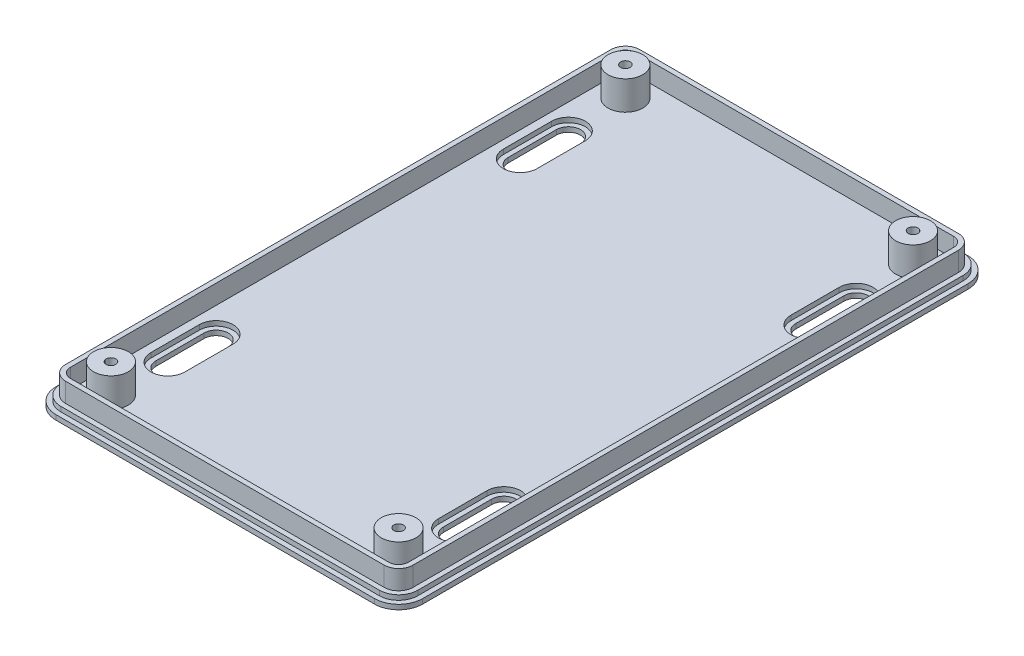
from build123d import *

# Parameters (mm, degrees)
SKETCH1_W           = 76
SKETCH1_H           = 123
BOSS_EXTRUDE2_DEPTH = 2
SKETCH1_4_R         = 3.6
BOSS_EXTRUDE3_DEPTH = 6
FILLET1_R           = 5
CUT_EXTRUDE1_DEPTH  = 73.541367508
SKETCH3_R           = 1
CUT_EXTRUDE2_DEPTH  = 73.734104793
CUT_EXTRUDE4_DEPTH  = 1
BOSS_EXTRUDE4_DEPTH = 4


with BuildPart() as part:
    # Sketch1 → Boss-Extrude2 (new body)
    with BuildSketch(Plane(origin=(0, 0, 0), x_dir=(1, 0, 0), z_dir=(0, 1, 0))):
        Rectangle(SKETCH1_W, SKETCH1_H)
    extrude(amount=-BOSS_EXTRUDE2_DEPTH)

    # Sketch1_4 → Boss-Extrude3 (add)
    with BuildSketch(Plane(origin=(0, 0, 0), x_dir=(1, 0, 0), z_dir=(0, 1, 0))):
        with Locations((-29.8, 53.3)):
            Circle(SKETCH1_4_R)
        with Locations((29.8, 53.3)):
            Circle(SKETCH1_4_R)
        with Locations((29.8, -53.3)):
            Circle(SKETCH1_4_R)
        with Locations((-29.8, -53.3)):
            Circle(SKETCH1_4_R)
    extrude(amount=BOSS_EXTRUDE3_DEPTH)

    # Fillet1
    fillet1_edges = [part.edges().sort_by_distance(p)[0] for p in [
        (-38, -1, -61.5),
        (38, -1, -61.5),
        (38, -1, 61.5),
        (-38, -1, 61.5),
    ]]
    fillet(fillet1_edges, radius=FILLET1_R)

    # Sketch2 → Cut-Extrude1 (cut, through all)
    with BuildSketch(Plane(origin=(0, 0, 0), x_dir=(1, 0, 0), z_dir=(0, 1, 0))):
        with BuildLine():
            Line((-27.3, 41.5), (-27.3, 31.5))
            ThreePointArc((-27.3, 31.5), (-29.8, 29), (-32.3, 31.5))
            Line((-32.3, 31.5), (-32.3, 41.5))
            ThreePointArc((-32.3, 41.5), (-29.8, 44), (-27.3, 41.5))
        make_face()
        with BuildLine():
            Line((27.3, 41.5), (27.3, 31.5))
            ThreePointArc((27.3, 31.5), (29.8, 29), (32.3, 31.5))
            Line((32.3, 31.5), (32.3, 41.5))
            ThreePointArc((32.3, 41.5), (29.8, 44), (27.3, 41.5))
        make_face()
        with BuildLine():
            Line((-27.3, -41.5), (-27.3, -31.5))
            ThreePointArc((-27.3, -31.5), (-29.8, -29), (-32.3, -31.5))
            Line((-32.3, -31.5), (-32.3, -41.5))
            ThreePointArc((-32.3, -41.5), (-29.8, -44), (-27.3, -41.5))
        make_face()
        with BuildLine():
            Line((27.3, -41.5), (27.3, -31.5))
            ThreePointArc((27.3, -31.5), (29.8, -29), (32.3, -31.5))
            Line((32.3, -31.5), (32.3, -41.5))
            ThreePointArc((32.3, -41.5), (29.8, -44), (27.3, -41.5))
        make_face()
    extrude(amount=-CUT_EXTRUDE1_DEPTH, mode=Mode.SUBTRACT)

    # Sketch3 → Cut-Extrude2 (cut, through all)
    with BuildSketch(Plane(origin=(0, 6, 0), x_dir=(1, 0, 0), z_dir=(0, 1, 0))):
        with Locations((-29.8, -53.3)):
            Circle(SKETCH3_R)
        with Locations((29.8, -53.3)):
            Circle(SKETCH3_R)
        with Locations((29.8, 53.3)):
            Circle(SKETCH3_R)
        with Locations((-29.8, 53.3)):
            Circle(SKETCH3_R)
    extrude(amount=-CUT_EXTRUDE2_DEPTH, mode=Mode.SUBTRACT)

    # Sketch4 → Cut-Extrude4 (cut)
    # profile 1 of 5: a face of its own
    with BuildSketch(Plane(origin=(0, 0, 0), x_dir=(1, 0, 0), z_dir=(0, 1, 0))):
        with BuildLine():
            ThreePointArc((-38, -56.5), (-36.535533906, -60.035533906), (-33, -61.5))
            Line((-33, -61.5), (33, -61.5))
            ThreePointArc((33, -61.5), (36.535533906, -60.035533906), (38, -56.5))
            Line((38, -56.5), (38, 56.5))
            ThreePointArc((38, 56.5), (36.535533906, 60.035533906), (33, 61.5))
            Line((33, 61.5), (-33, 61.5))
            ThreePointArc((-33, 61.5), (-36.535533906, 60.035533906), (-38, 56.5))
            Line((-38, 56.5), (-38, -56.5))
        make_face()
        with BuildLine():
            Line((33, -60.5), (-33, -60.5))
            ThreePointArc((-33, -60.5), (-35.828427125, -59.328427125), (-37, -56.5))
            Line((-37, -56.5), (-37, 56.5))
            ThreePointArc((-37, 56.5), (-35.828427125, 59.328427125), (-33, 60.5))
            Line((-33, 60.5), (33, 60.5))
            ThreePointArc((33, 60.5), (35.828427125, 59.328427125), (37, 56.5))
            Line((37, 56.5), (37, -56.5))
            ThreePointArc((37, -56.5), (35.828427125, -59.328427125), (33, -60.5))
        make_face(mode=Mode.SUBTRACT)
    # profile 2 of 5: a face of its own
    with BuildSketch(Plane(origin=(0, 0, 0), x_dir=(1, 0, 0), z_dir=(0, 1, 0))):
        with BuildLine():
            ThreePointArc((26.3, 31.5), (29.8, 28), (33.3, 31.5))
            Line((33.3, 31.5), (33.3, 41.5))
            ThreePointArc((33.3, 41.5), (29.8, 45), (26.3, 41.5))
            Line((26.3, 41.5), (26.3, 31.5))
        make_face()
        with BuildLine():
            Line((32.3, 41.5), (32.3, 31.5))
            ThreePointArc((32.3, 31.5), (29.8, 29), (27.3, 31.5))
            Line((27.3, 31.5), (27.3, 41.5))
            ThreePointArc((27.3, 41.5), (29.8, 44), (32.3, 41.5))
        make_face(mode=Mode.SUBTRACT)
    # profile 3 of 5: a face of its own
    with BuildSketch(Plane(origin=(0, 0, 0), x_dir=(1, 0, 0), z_dir=(0, 1, 0))):
        with BuildLine():
            ThreePointArc((-33.3, 31.5), (-29.8, 28), (-26.3, 31.5))
            Line((-26.3, 31.5), (-26.3, 41.5))
            ThreePointArc((-26.3, 41.5), (-29.8, 45), (-33.3, 41.5))
            Line((-33.3, 41.5), (-33.3, 31.5))
        make_face()
        with BuildLine():
            Line((-27.3, 41.5), (-27.3, 31.5))
            ThreePointArc((-27.3, 31.5), (-29.8, 29), (-32.3, 31.5))
            Line((-32.3, 31.5), (-32.3, 41.5))
            ThreePointArc((-32.3, 41.5), (-29.8, 44), (-27.3, 41.5))
        make_face(mode=Mode.SUBTRACT)
    # profile 4 of 5: a face of its own
    with BuildSketch(Plane(origin=(0, 0, 0), x_dir=(1, 0, 0), z_dir=(0, 1, 0))):
        with BuildLine():
            ThreePointArc((-26.3, -31.5), (-29.8, -28), (-33.3, -31.5))
            Line((-33.3, -31.5), (-33.3, -41.5))
            ThreePointArc((-33.3, -41.5), (-29.8, -45), (-26.3, -41.5))
            Line((-26.3, -41.5), (-26.3, -31.5))
        make_face()
        with BuildLine():
            Line((-32.3, -41.5), (-32.3, -31.5))
            ThreePointArc((-32.3, -31.5), (-29.8, -29), (-27.3, -31.5))
            Line((-27.3, -31.5), (-27.3, -41.5))
            ThreePointArc((-27.3, -41.5), (-29.8, -44), (-32.3, -41.5))
        make_face(mode=Mode.SUBTRACT)
    # profile 5 of 5: a face of its own
    with BuildSketch(Plane(origin=(0, 0, 0), x_dir=(1, 0, 0), z_dir=(0, 1, 0))):
        with BuildLine():
            ThreePointArc((26.3, -41.5), (29.8, -45), (33.3, -41.5))
            Line((33.3, -41.5), (33.3, -31.5))
            ThreePointArc((33.3, -31.5), (29.8, -28), (26.3, -31.5))
            Line((26.3, -31.5), (26.3, -41.5))
        make_face()
        with BuildLine():
            Line((32.3, -31.5), (32.3, -41.5))
            ThreePointArc((32.3, -41.5), (29.8, -44), (27.3, -41.5))
            Line((27.3, -41.5), (27.3, -31.5))
            ThreePointArc((27.3, -31.5), (29.8, -29), (32.3, -31.5))
        make_face(mode=Mode.SUBTRACT)
    extrude(amount=-CUT_EXTRUDE4_DEPTH, mode=Mode.SUBTRACT)

    # Sketch5 → Boss-Extrude4 (add)
    with BuildSketch(Plane(origin=(0, 0, 0), x_dir=(1, 0, 0), z_dir=(0, 1, 0))):
        with BuildLine():
            Line((-36, 56.5), (-36, -56.5))
            ThreePointArc((-36, -56.5), (-35.121320344, -58.621320344), (-33, -59.5))
            Line((-33, -59.5), (33, -59.5))
            ThreePointArc((33, -59.5), (35.121320344, -58.621320344), (36, -56.5))
            Line((36, -56.5), (36, 56.5))
            ThreePointArc((36, 56.5), (35.121320344, 58.621320344), (33, 59.5))
            Line((33, 59.5), (-33, 59.5))
            ThreePointArc((-33, 59.5), (-35.121320344, 58.621320344), (-36, 56.5))
        make_face()
        with BuildLine():
            Line((-35, 56.5), (-35, -56.5))
            ThreePointArc((-35, -56.5), (-34.414213562, -57.914213562), (-33, -58.5))
            Line((-33, -58.5), (33, -58.5))
            ThreePointArc((33, -58.5), (34.414213562, -57.914213562), (35, -56.5))
            Line((35, -56.5), (35, 56.5))
            ThreePointArc((35, 56.5), (34.414213562, 57.914213562), (33, 58.5))
            Line((33, 58.5), (-33, 58.5))
            ThreePointArc((-33, 58.5), (-34.414213562, 57.914213562), (-35, 56.5))
        make_face(mode=Mode.SUBTRACT)
    extrude(amount=BOSS_EXTRUDE4_DEPTH)


solid = part.part
